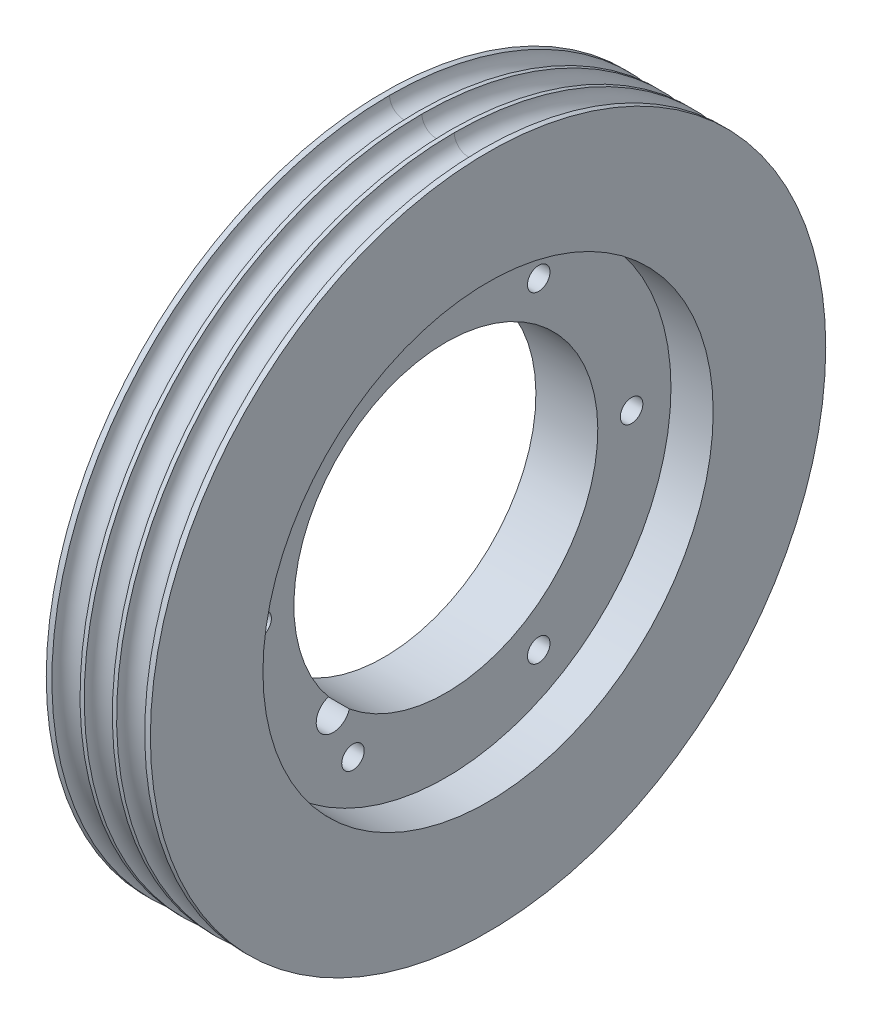
from build123d import *

# Parameters (mm, degrees)
SKETCH1_R           = 60
BOSS_EXTRUDE1_DEPTH = 9.25
SKETCH3_R           = 27
CUT_EXTRUDE1_DEPTH  = 15
SKETCH4_R           = 2
CUT_EXTRUDE2_DEPTH  = 15
SKETCH5_R           = 4
CUT_EXTRUDE3_DEPTH  = 3
CIRPATTERN1_COUNT   = 6
CUT_EXTRUDE4_REACH  = 88.846
SKETCH6_R           = 3
SKETCH7_R           = 2.5
SKETCH8_R           = 40
CUT_EXTRUDE5_DEPTH  = 7.5


with BuildPart() as part:
    # Sketch1 → Boss-Extrude1 (new, symmetric)
    with BuildSketch(Plane(origin=(0, 0, 0), x_dir=(0, 0, -1), z_dir=(1, 0, 0))):
        Circle(SKETCH1_R)
    extrude(amount=BOSS_EXTRUDE1_DEPTH, both=True)

    # Sketch3 → Cut-Extrude1 (cut)
    with BuildSketch(Plane.ZY.offset(9.25)):
        Circle(SKETCH3_R)
    extrude(amount=-CUT_EXTRUDE1_DEPTH, mode=Mode.SUBTRACT)

    # Sketch4 → Cut-Extrude2 (cut)
    with BuildSketch(Plane.ZY.offset(9.25)):
        with Locations((33, 0)):
            Circle(SKETCH4_R)
    cut_extrude2 = extrude(amount=-CUT_EXTRUDE2_DEPTH, mode=Mode.SUBTRACT)

    # Sketch5 → Cut-Extrude3 (cut)
    with BuildSketch(Plane.ZY.offset(9.25)):
        with Locations((33, 0)):
            Circle(SKETCH5_R)
    cut_extrude3 = extrude(amount=-CUT_EXTRUDE3_DEPTH, mode=Mode.SUBTRACT)

    # CirPattern1: Cut-Extrude2, Cut-Extrude3 ×6 about axis
    cirpattern1_axis = Axis((0, 0, 0), (1, 0, 0))
    add([cut_extrude2.rotate(cirpattern1_axis, i * 360 / CIRPATTERN1_COUNT) for i in range(1, CIRPATTERN1_COUNT)], mode=Mode.SUBTRACT)
    add([cut_extrude3.rotate(cirpattern1_axis, i * 360 / CIRPATTERN1_COUNT) for i in range(1, CIRPATTERN1_COUNT)], mode=Mode.SUBTRACT)

    # Sketch6 → Cut-Extrude4 (cut, up to next)
    with BuildSketch(Plane.ZY.offset(9.25), mode=Mode.PRIVATE) as cut_extrude4_sk1:
        with Locations(Location((20.032335111, -20.032335111, 0), (0, 0, 74.069764845))):
            Circle(SKETCH6_R)
    cut_extrude4_tool1 = extrude(cut_extrude4_sk1.sketch, amount=-CUT_EXTRUDE4_REACH, mode=Mode.PRIVATE) & part.part
    add(cut_extrude4_tool1.solids().sort_by_distance((-9.25, -20.032335, 20.032335))[0], mode=Mode.SUBTRACT)

    # Cut-Sweep1: sweep along a curve in space
    with BuildLine() as cut_sweep1_path:
        ThreePointArc((-9.25, 0, -60), (-9.25, 42.426406871, -42.426406871), (-9.25, 60, 0))
        ThreePointArc((-9.25, 60, 0), (-9.25, 42.426406871, 42.426406871), (-9.25, 0, 60))
        ThreePointArc((-9.25, 0, 60), (-9.25, -42.426406871, 42.426406871), (-9.25, -60, 0))
        ThreePointArc((-9.25, -60, 0), (-9.25, -42.426406871, -42.426406871), (-9.25, 0, -60))
    # Sketch7 → Cut-Sweep1 (sweep, cut)
    with BuildSketch(Plane.XY):
        with Locations((5.75, 60.007104411)):
            Circle(SKETCH7_R)
        with Locations((-5.75, 60.007104411)):
            Circle(SKETCH7_R)
        with Locations((0, 60.007104411)):
            Circle(SKETCH7_R)
    sweep(path=cut_sweep1_path.line, mode=Mode.SUBTRACT)

    # Sketch8 → Cut-Extrude5 (cut)
    with BuildSketch(Plane(origin=(9.25, 0, 0), x_dir=(0, 0, -1), z_dir=(1, 0, 0))):
        Circle(SKETCH8_R)
    extrude(amount=-CUT_EXTRUDE5_DEPTH, mode=Mode.SUBTRACT)


solid = part.part
